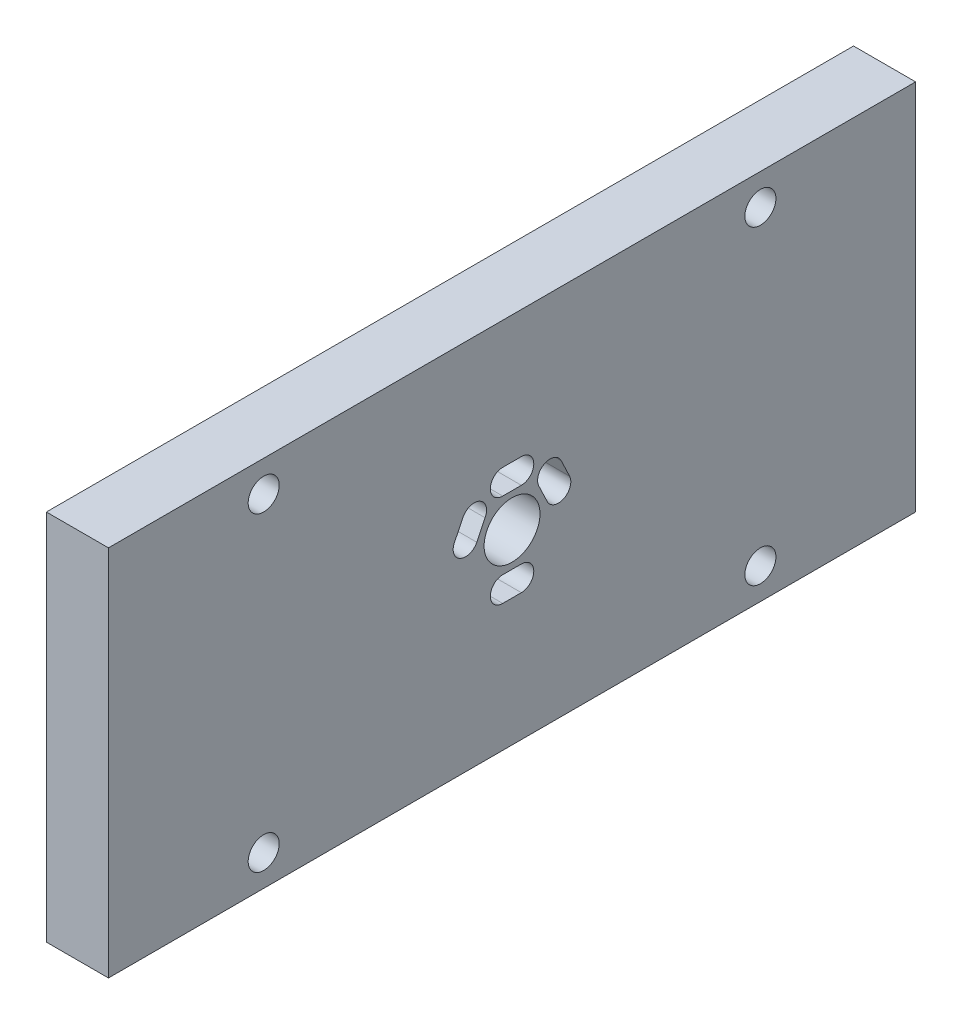
from build123d import *

# Parameters (mm, degrees)
SKETCH1_W           = 130
SKETCH1_H           = 60
SKETCH1_R           = 2.5
SKETCH1_R_2         = 4.499999999
BOSS_EXTRUDE1_DEPTH = 10


with BuildPart() as part:
    # Sketch1 → Boss-Extrude1 (new body)
    with BuildSketch(Plane(origin=(0, 0, 0), x_dir=(0, 0, -1), z_dir=(1, 0, 0))):
        with Locations((3.813160791, 27.897530874)):
            Rectangle(SKETCH1_W, SKETCH1_H)
        with Locations((-36.186839209, 52.897530874)):
            Circle(SKETCH1_R, mode=Mode.SUBTRACT)
        with Locations((-36.186839209, 2.897530874)):
            Circle(SKETCH1_R, mode=Mode.SUBTRACT)
        with Locations((43.813160791, 2.897530874)):
            Circle(SKETCH1_R, mode=Mode.SUBTRACT)
        with Locations((43.813160791, 52.897530874)):
            Circle(SKETCH1_R, mode=Mode.SUBTRACT)
        with Locations((3.813160791, 27.897530874)):
            Circle(SKETCH1_R_2, mode=Mode.SUBTRACT)
        with BuildLine():
            Line((-5.464379102, 30.775341326), (-4.081605515, 33.606305024))
            ThreePointArc((-4.081605515, 33.606305024), (-1.369183898, 34.499769949), (-0.528409533, 31.770555947))
            Line((-0.528409533, 31.770555947), (-1.869576404, 29.020756356))
            ThreePointArc((-1.869576404, 29.020756356), (-4.544523089, 28.10012945), (-5.464379102, 30.775341326))
        make_face(mode=Mode.SUBTRACT)
        with BuildLine():
            Line((5.31316079, 18.397530874), (2.313160791, 18.397530874))
            ThreePointArc((2.313160791, 18.397530874), (0.313160792, 20.397530874), (2.313160791, 22.397530873))
            Line((2.313160791, 22.397530873), (5.31316079, 22.397530873))
            ThreePointArc((5.31316079, 22.397530873), (7.313160789, 20.397530874), (5.31316079, 18.397530874))
        make_face(mode=Mode.SUBTRACT)
        with BuildLine():
            Line((5.31316079, 33.374248764), (2.313160791, 33.374248764))
            ThreePointArc((2.313160791, 33.374248764), (0.31316079, 35.374248765), (2.313160791, 37.374248765))
            Line((2.313160791, 37.374248765), (5.31316079, 37.374248765))
            ThreePointArc((5.31316079, 37.374248765), (7.313160791, 35.374248765), (5.31316079, 33.374248764))
        make_face(mode=Mode.SUBTRACT)
        with BuildLine():
            Line((9.471997672, 29.038205562), (8.081045524, 31.961596177))
            ThreePointArc((8.081045524, 31.961596177), (9.113942414, 34.555839775), (11.733632625, 33.589300054))
            Line((11.733632625, 33.589300054), (13.083423708, 30.758314735))
            ThreePointArc((13.083423708, 30.758314735), (12.137765277, 28.092547131), (9.471997672, 29.038205562))
        make_face(mode=Mode.SUBTRACT)
    extrude(amount=BOSS_EXTRUDE1_DEPTH)


solid = part.part
